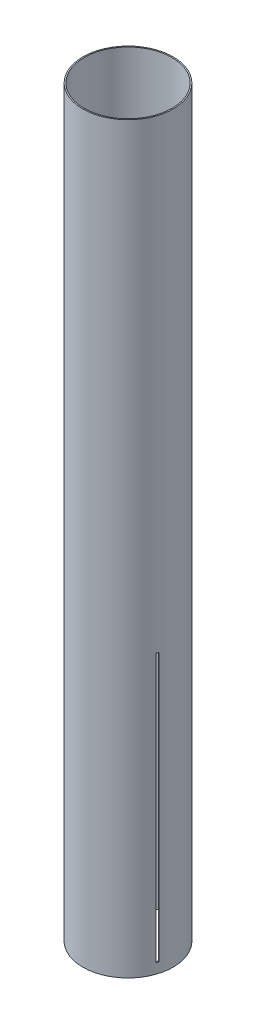
from build123d import *

# Parameters (mm, degrees)
SKETCH2_R           = 50.9524
SKETCH2_R_2         = 49.5808
BOSS_EXTRUDE1_DEPTH = 838.2
SKETCH3_W           = 2.9972
SKETCH3_H           = 302.26
CUT_EXTRUDE1_DEPTH  = 51.9524
CIRPATTERN2_COUNT   = 3


with BuildPart() as part:
    # Sketch2 → Boss-Extrude1 (new body)
    with BuildSketch(Plane(origin=(0, 0, 0), x_dir=(1, 0, 0), z_dir=(0, 1, 0))):
        Circle(SKETCH2_R)
        Circle(SKETCH2_R_2, mode=Mode.SUBTRACT)
    extrude(amount=BOSS_EXTRUDE1_DEPTH)

    # Sketch3 → Cut-Extrude1 (cut, through all)
    with BuildSketch(Plane.XY):
        with Locations((-11.027101343, 162.4838)):
            Rectangle(SKETCH3_W, SKETCH3_H)
    cut_extrude1 = extrude(amount=-CUT_EXTRUDE1_DEPTH, mode=Mode.SUBTRACT)

    # CirPattern2: Cut-Extrude1 ×3 about axis
    cirpattern2_axis = Axis((0, 0, 0), (0, 1, 0))
    for i in range(1, CIRPATTERN2_COUNT):
        add(cut_extrude1.rotate(cirpattern2_axis, i * 360 / CIRPATTERN2_COUNT), mode=Mode.SUBTRACT)


solid = part.part
